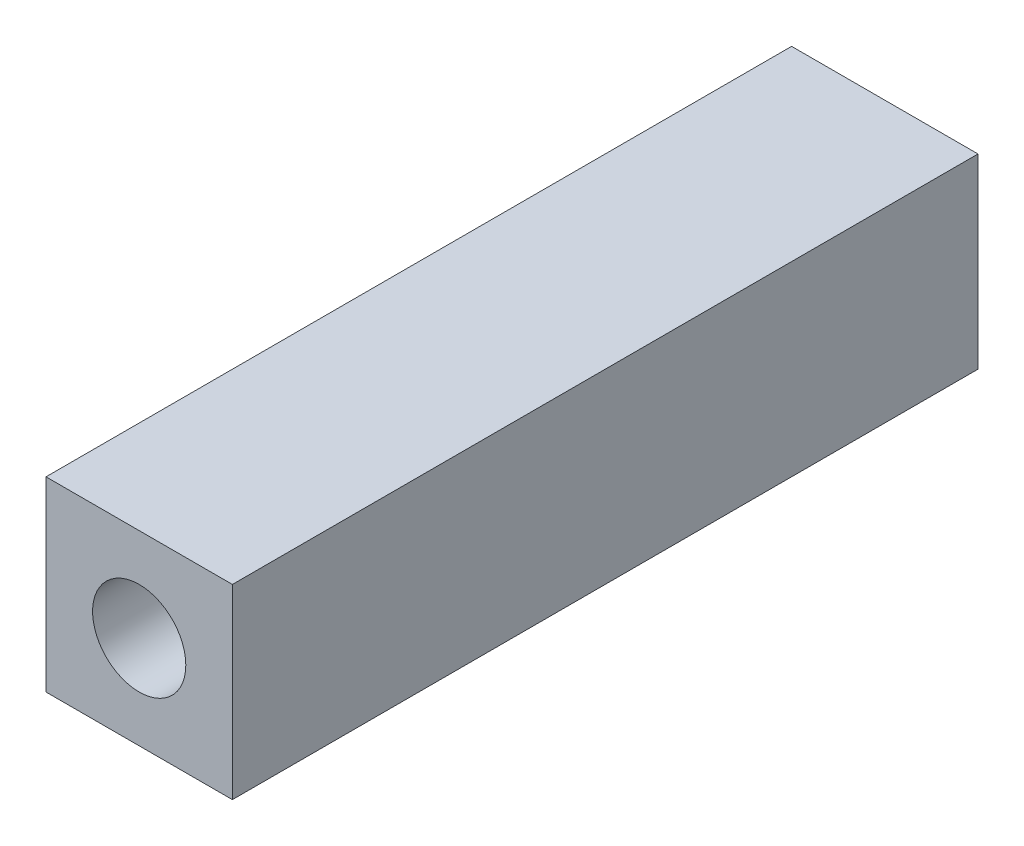
from build123d import *

# Parameters (mm, degrees)
SKETCH1_W           = 10
SKETCH1_H           = 10
SKETCH1_R           = 2.5
BOSS_EXTRUDE1_DEPTH = 40


with BuildPart() as part:
    # Sketch1 → Boss-Extrude1 (new body)
    with BuildSketch(Plane.XY):
        Rectangle(SKETCH1_W, SKETCH1_H)
        Circle(SKETCH1_R, mode=Mode.SUBTRACT)
    extrude(amount=BOSS_EXTRUDE1_DEPTH)


solid = part.part
